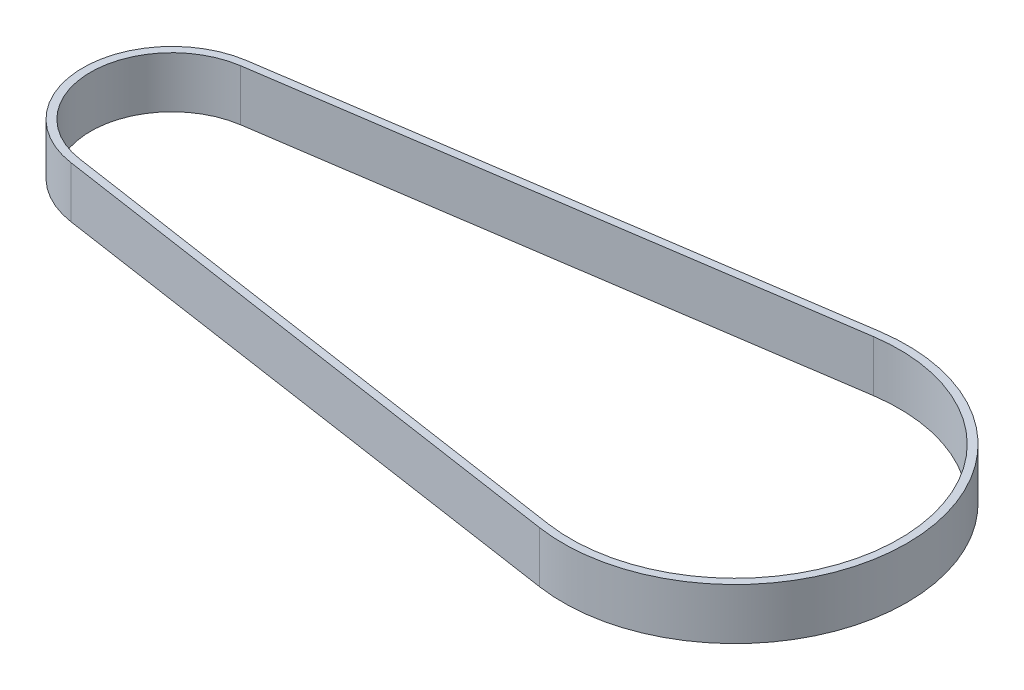
from build123d import *

# Parameters (mm, degrees)
BOSS_EXTRUDE1_DEPTH = 10


with BuildPart() as part:
    # Sketch1 → Boss-Extrude1 (new body)
    with BuildSketch(Plane(origin=(0, 0, 0), x_dir=(1, 0, 0), z_dir=(0, 1, 0))):
        with BuildLine():
            Line((-74.174598733, -17.22581201), (33.448411267, -33.220149087))
            ThreePointArc((33.448411267, -33.220149087), (71.970406267, 0), (33.448411267, 33.220149087))
            Line((33.448411267, 33.220149087), (-74.174598733, 17.22581201))
            ThreePointArc((-74.174598733, 17.22581201), (-89.029593733, 0), (-74.174598733, -17.22581201))
        make_face()
        with BuildLine():
            Line((-73.954098733, 15.742107272), (33.668911267, 31.736444349))
            ThreePointArc((33.668911267, 31.736444349), (70.470406267, 0), (33.668911267, -31.736444349))
            Line((33.668911267, -31.736444349), (-73.954098733, -15.742107272))
            ThreePointArc((-73.954098733, -15.742107272), (-87.529593733, 0), (-73.954098733, 15.742107272))
        make_face(mode=Mode.SUBTRACT)
    extrude(amount=BOSS_EXTRUDE1_DEPTH)


solid = part.part
